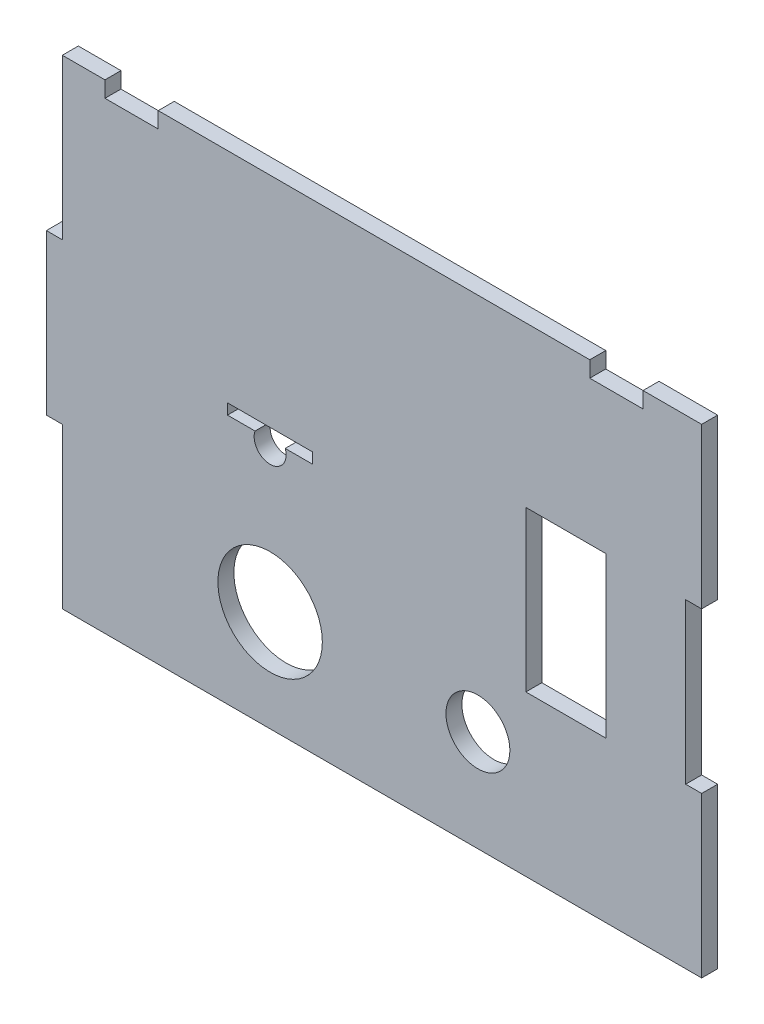
from build123d import *

# Parameters (mm, degrees)
MODEL_R             = 9.8
MODEL_R_2           = 6
MODEL_W             = 15
MODEL_H             = 30
BOSS_EXTRUDE1_DEPTH = 3


with BuildPart() as part:
    # Model → Boss-Extrude1 (new body)
    with BuildSketch(Plane.XY):
        Polygon((-160.191927583, -27), (-160.191927583, -57), (-157.191927583, -57), (-157.191927583, -87), (-277.191927583, -87), (-277.191927583, -57), (-280.191927583, -57), (-280.191927583, -27), (-277.191927583, -27), (-277.191927583, 3), (-269.191927583, 3), (-269.191927583, 0), (-259.191927583, 0), (-259.191927583, 3), (-178.191927583, 3), (-178.191927583, 0), (-168.191927583, 0), (-168.191927583, 3), (-157.191927583, 3), (-157.191927583, -27), align=None)
        with Locations((-238.191927583, -68)):
            Circle(MODEL_R, mode=Mode.SUBTRACT)
        with Locations((-199.191927583, -68)):
            Circle(MODEL_R_2, mode=Mode.SUBTRACT)
        with Locations((-182.691927583, -42)):
            Rectangle(MODEL_W, MODEL_H, mode=Mode.SUBTRACT)
        with BuildLine():
            Line((-235.363500459, -40), (-230.191927583, -40))
            Line((-230.191927583, -40), (-230.191927583, -38))
            Line((-230.191927583, -38), (-246.191927583, -38))
            Line((-246.191927583, -38), (-246.191927583, -40))
            Line((-246.191927583, -40), (-241.020354708, -40))
            ThreePointArc((-241.020354708, -40), (-238.191927583, -44), (-235.363500459, -40))
        make_face(mode=Mode.SUBTRACT)
    extrude(amount=BOSS_EXTRUDE1_DEPTH)


solid = part.part
